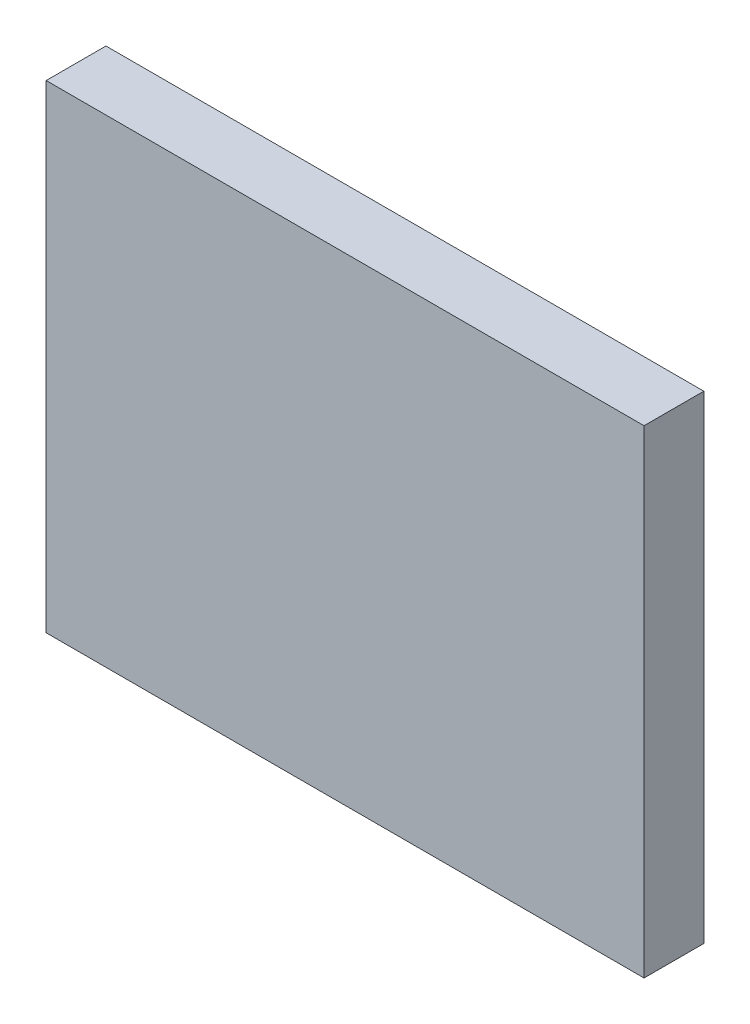
from build123d import *

# Parameters (mm, degrees)
SKETCH1_W           = 50
SKETCH1_H           = 40
BOSS_EXTRUDE1_DEPTH = 5


with BuildPart() as part:
    # Sketch1 → Boss-Extrude1 (new body)
    with BuildSketch(Plane.XY):
        with Locations((4.411764706, -10.792838875)):
            Rectangle(SKETCH1_W, SKETCH1_H)
    extrude(amount=BOSS_EXTRUDE1_DEPTH)


solid = part.part
